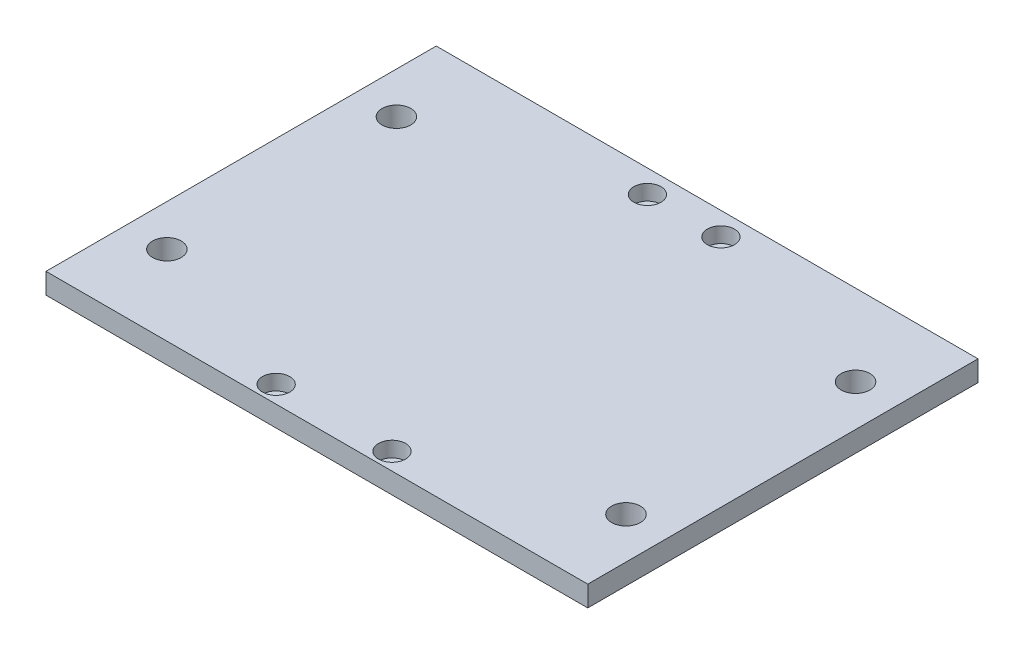
from build123d import *

# Parameters (mm, degrees)
SKETCH1_W                                            = 119.888
SKETCH1_H                                            = 86.36
BOSS_EXTRUDE1_DEPTH                                  = 4.572
CBORE_FOR_M3_HEXAGON_SOCKET_HEAD_CAP_SCR_D           = 3.4
CBORE_FOR_M3_HEXAGON_SOCKET_HEAD_CAP_SCR_CBORE_D     = 6
CBORE_FOR_M3_HEXAGON_SOCKET_HEAD_CAP_SCR_CBORE_DEPTH = 3.4
SKETCH5_R                                            = 3.175
CUT_EXTRUDE1_DEPTH                                   = 5.572


with BuildPart() as part:
    # Sketch1 → Boss-Extrude1 (new body)
    with BuildSketch(Plane(origin=(0, 0, 0), x_dir=(1, 0, 0), z_dir=(0, 1, 0))):
        Rectangle(SKETCH1_W, SKETCH1_H)
    extrude(amount=BOSS_EXTRUDE1_DEPTH)

    # CBORE for M3 Hexagon socket head cap screws1 (through all)
    with Locations(Plane(origin=(0, 4.572, 0), x_dir=(1, 0, 0), z_dir=(0, 1, 0))):
        with Locations((8.128, 38.1), (12.827, -39.37), (-12.827, -39.37), (-8.128, 38.1)):
            CounterBoreHole(CBORE_FOR_M3_HEXAGON_SOCKET_HEAD_CAP_SCR_D / 2, CBORE_FOR_M3_HEXAGON_SOCKET_HEAD_CAP_SCR_CBORE_D / 2, CBORE_FOR_M3_HEXAGON_SOCKET_HEAD_CAP_SCR_CBORE_DEPTH)

    # Sketch5 → Cut-Extrude1 (cut, through all)
    with BuildSketch(Plane(origin=(0, 4.572, 0), x_dir=(1, 0, 0), z_dir=(0, 1, 0))):
        with Locations((50.8, 25.225713352)):
            Circle(SKETCH5_R)
        with Locations((50.8, -25.574286648)):
            Circle(SKETCH5_R)
        with Locations((-50.8, 25.225713352)):
            Circle(SKETCH5_R)
        with Locations((-50.8, -25.574286648)):
            Circle(SKETCH5_R)
    extrude(amount=-CUT_EXTRUDE1_DEPTH, mode=Mode.SUBTRACT)


solid = part.part
